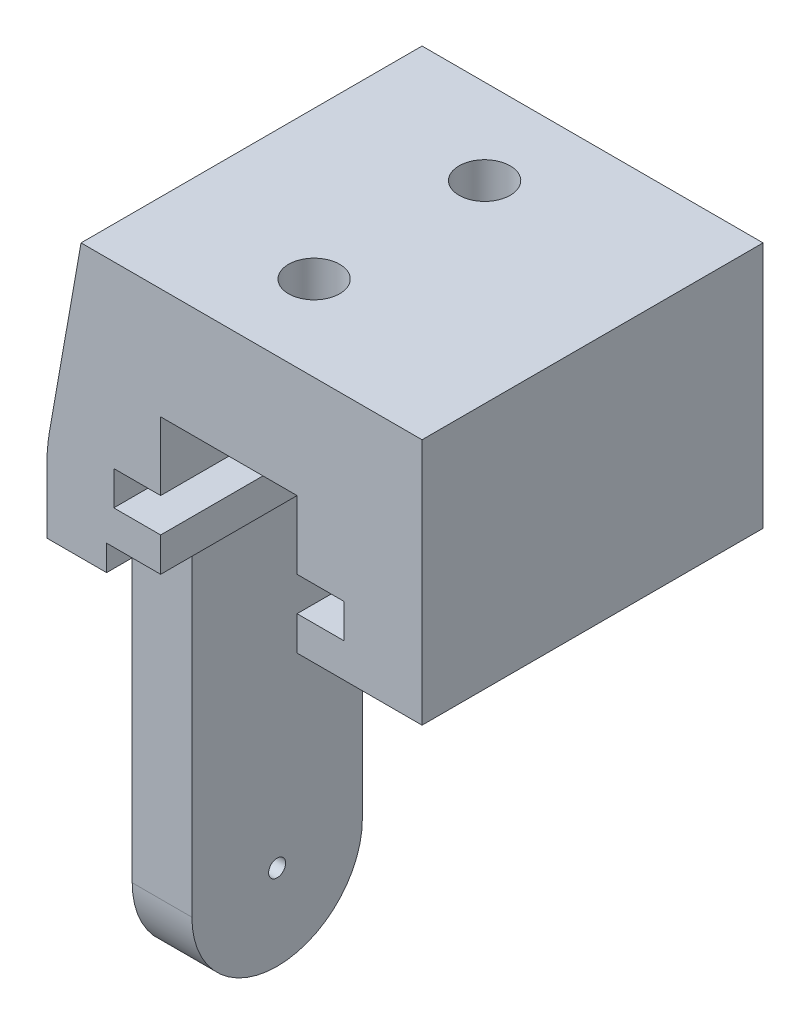
from build123d import *

# Parameters (mm, degrees)
SKETCH1_W           = 22
SKETCH1_H           = 16
BOSS_EXTRUDE1_DEPTH = 20
CHAMFER1_SIZE       = 2
CHAMFER1_SIZE2      = 11.342563639
CUT_EXTRUDE1_DEPTH  = 20
FILLET1_R           = 10
SKETCH3_W           = 3.5
SKETCH3_H           = 10
BOSS_EXTRUDE2_DEPTH = 20
FILLET2_R           = 1
BOSS_EXTRUDE3_DEPTH = 3.5
SKETCH8_R           = 0.5
CUT_EXTRUDE2_DEPTH  = 3.5
SKETCH9_R           = 1.5
CUT_EXTRUDE3_DEPTH  = 6.5


with BuildPart() as part:
    # Sketch1 → Boss-Extrude1 (new body)
    with BuildSketch(Plane.XY):
        with Locations((11, -8)):
            Rectangle(SKETCH1_W, SKETCH1_H)
    extrude(amount=BOSS_EXTRUDE1_DEPTH)

    # Chamfer1
    chamfer1_edges = [part.edges().sort_by_distance(p)[0] for p in [
        (0, 0, 10),
    ]]
    chamfer1_side = [part.faces().sort_by_distance(p)[0] for p in [
        (11, 0, 10),
    ]]
    chamfer(chamfer1_edges, length=CHAMFER1_SIZE, length2=CHAMFER1_SIZE2, reference=chamfer1_side[0])

    # Sketch2 → Cut-Extrude1 (cut)
    with BuildSketch(Plane.XY.offset(20)):
        Polygon((3.5, -16), (3.5, -14.5), (6.67, -14.5), (6.67, -12.5), (3.92, -12.5), (3.92, -10.5), (6.67, -10.5), (6.67, -6.5), (14.67, -6.5), (14.67, -10.5), (17.42, -10.5), (17.42, -12.5), (14.67, -12.5), (14.67, -14.5), (22, -14.5), (22, -16), align=None)
    extrude(amount=-CUT_EXTRUDE1_DEPTH, mode=Mode.SUBTRACT)

    # Fillet1
    fillet1_edges = [part.edges().sort_by_distance(p)[0] for p in [
        (0, -11.342563639, 10),
    ]]
    fillet(fillet1_edges, radius=FILLET1_R)

    # Sketch3 → Boss-Extrude2 (add)
    with BuildSketch(Plane.XZ.offset(16)):
        with Locations((1.75, 10)):
            Rectangle(SKETCH3_W, SKETCH3_H)
    extrude(amount=BOSS_EXTRUDE2_DEPTH)

    # Fillet2
    fillet2_edges = [part.edges().sort_by_distance(p)[0] for p in [
        (1.75, -16, 5),
        (1.75, -16, 15),
    ]]
    fillet(fillet2_edges, radius=FILLET2_R)

    # Sketch7 → Boss-Extrude3 (add)
    with BuildSketch(Plane.ZY):
        with BuildLine():
            Line((15, -36), (5, -36))
            ThreePointArc((5, -36), (10, -41), (15, -36))
        make_face()
    extrude(amount=-BOSS_EXTRUDE3_DEPTH)

    # Sketch8 → Cut-Extrude2 (cut)
    with BuildSketch(Plane.ZY):
        with Locations((10, -36)):
            Circle(SKETCH8_R)
    extrude(amount=-CUT_EXTRUDE2_DEPTH, mode=Mode.SUBTRACT)

    # Sketch9 → Cut-Extrude3 (cut)
    with BuildSketch(Plane.XZ.offset(6.5)):
        with Locations((10.67, 15)):
            Circle(SKETCH9_R)
        with Locations((10.67, 5)):
            Circle(SKETCH9_R)
    extrude(amount=-CUT_EXTRUDE3_DEPTH, mode=Mode.SUBTRACT)


solid = part.part
